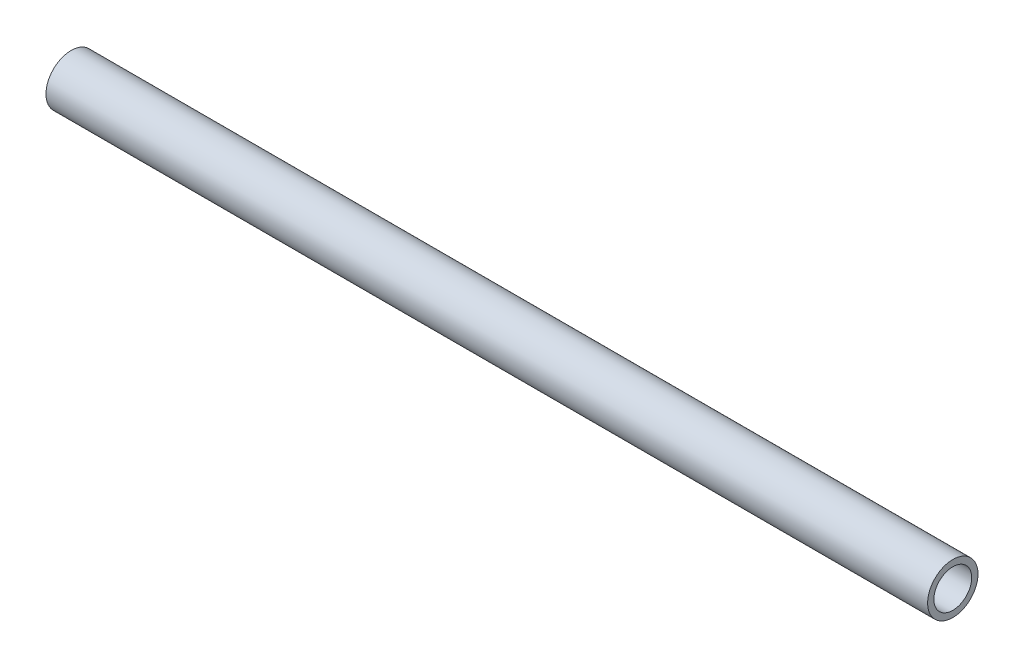
from build123d import *

# Parameters (mm, degrees)
SKETCH1_R           = 8
SKETCH1_R_2         = 6
BOSS_EXTRUDE1_DEPTH = 140


with BuildPart() as part:
    # Sketch1 → Boss-Extrude1 (new body, symmetric)
    with BuildSketch(Plane(origin=(0, 0, 0), x_dir=(0, 0, -1), z_dir=(1, 0, 0))):
        Circle(SKETCH1_R)
        Circle(SKETCH1_R_2, mode=Mode.SUBTRACT)
    extrude(amount=BOSS_EXTRUDE1_DEPTH, both=True)


solid = part.part
